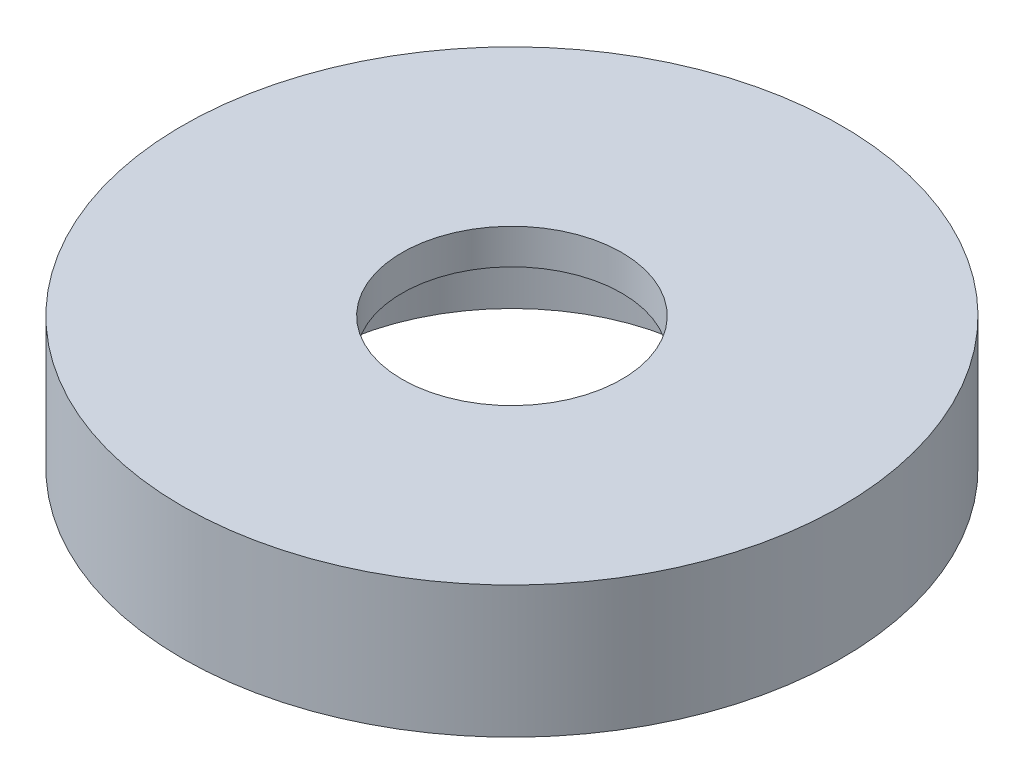
from build123d import *

# Parameters (mm, degrees)
SKETCH1_R           = 95.25
BOSS_EXTRUDE1_DEPTH = 19.05
SKETCH2_R           = 31.75
CUT_EXTRUDE1_DEPTH  = 10.16
SKETCH3_R           = 56.515
CUT_EXTRUDE2_DEPTH  = 27.94
SKETCH4_R           = 3.175
CUT_EXTRUDE3_DEPTH  = 19.05
CIRPATTERN1_COUNT   = 3


with BuildPart() as part:
    # Sketch1 → Boss-Extrude1 (new body, symmetric)
    with BuildSketch(Plane(origin=(0, 0, 0), x_dir=(1, 0, 0), z_dir=(0, 1, 0))):
        Circle(SKETCH1_R)
    extrude(amount=BOSS_EXTRUDE1_DEPTH, both=True)

    # Sketch2 → Cut-Extrude1 (cut)
    with BuildSketch(Plane(origin=(0, 19.05, 0), x_dir=(1, 0, 0), z_dir=(0, 1, 0))):
        Circle(SKETCH2_R)
    extrude(amount=-CUT_EXTRUDE1_DEPTH, mode=Mode.SUBTRACT)

    # Sketch3 → Cut-Extrude2 (cut)
    with BuildSketch(Plane.XZ.offset(19.05)):
        Circle(SKETCH3_R)
    extrude(amount=-CUT_EXTRUDE2_DEPTH, mode=Mode.SUBTRACT)

    # Sketch4 → Cut-Extrude3 (cut)
    with BuildSketch(Plane.XZ.offset(19.05)):
        with Locations((-76.2, 0)):
            Circle(SKETCH4_R)
    cut_extrude3 = extrude(amount=-CUT_EXTRUDE3_DEPTH, mode=Mode.SUBTRACT)

    # CirPattern1: Cut-Extrude3 ×3 about axis
    cirpattern1_axis = Axis((0, 0, 0), (0, 1, 0))
    for i in range(1, CIRPATTERN1_COUNT):
        add(cut_extrude3.rotate(cirpattern1_axis, i * 360 / CIRPATTERN1_COUNT), mode=Mode.SUBTRACT)


solid = part.part
